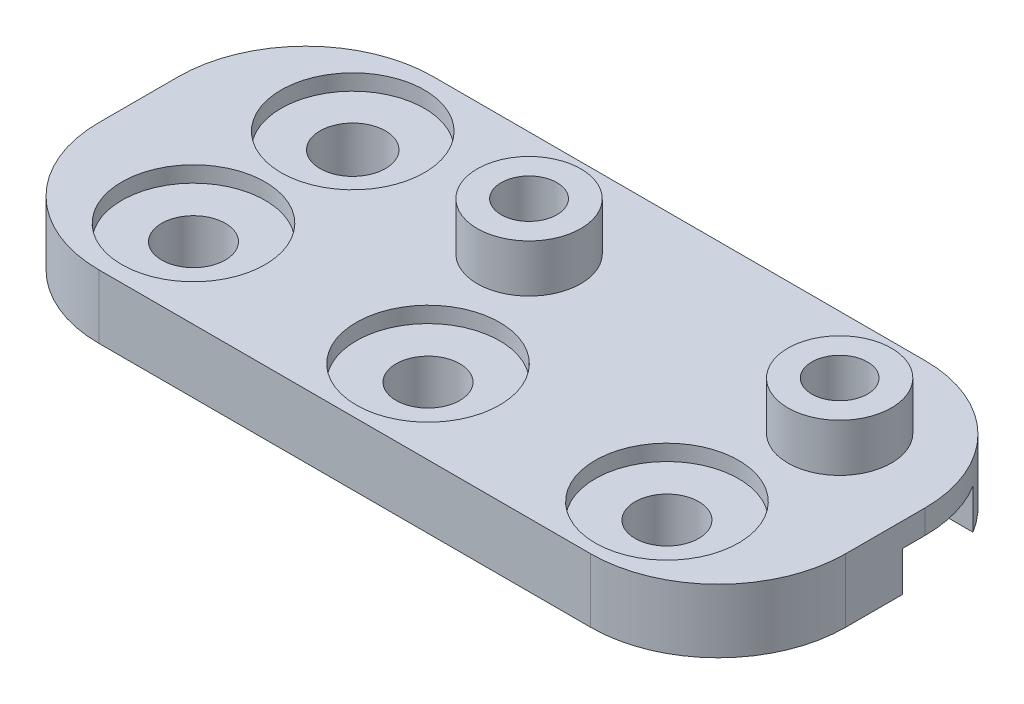
from build123d import *

# Parameters (mm, degrees)
SKETCH2_W           = 46.883828082
SKETCH2_H           = 21
SKETCH2_R           = 2
SKETCH2_R_2         = 2.054050428
SKETCH2_R_3         = 3.25
BOSS_EXTRUDE2_DEPTH = 4
SKETCH2_2_R         = 3.25
BOSS_EXTRUDE3_DEPTH = 7
CUT_EXTRUDE1_REACH  = 9
SKETCH1_R           = 1.75
HOLE1_D             = 4
HOLE1_DEPTH         = 4
HOLE1_CBORE_D       = 9
HOLE1_CBORE_DEPTH   = 1
FILLET1_R           = 8
SKETCH6_R           = 1.75
CUT_EXTRUDE2_DEPTH  = 2.5


with BuildPart() as part:
    # Sketch2 → Boss-Extrude2 (new body)
    with BuildSketch(Plane(origin=(0, 0, 0), x_dir=(1, 0, 0), z_dir=(0, 1, 0))):
        with Locations((0, 1.329477691)):
            Rectangle(SKETCH2_W, SKETCH2_H)
        with Locations((-14.997509842, -3.670522309)):
            Circle(SKETCH2_R, mode=Mode.SUBTRACT)
        with Locations((-14.997509842, 6.329477691)):
            Circle(SKETCH2_R_2, mode=Mode.SUBTRACT)
        with Locations((-2.8, 5.2)):
            Circle(SKETCH2_R_3, mode=Mode.SUBTRACT)
        with Locations((0, -3.943832634)):
            Circle(SKETCH2_R, mode=Mode.SUBTRACT)
        with Locations((16.7, 5.2)):
            Circle(SKETCH2_R_3, mode=Mode.SUBTRACT)
    extrude(amount=BOSS_EXTRUDE2_DEPTH)

    # Sketch2_2 → Boss-Extrude3 (add)
    with BuildSketch(Plane(origin=(0, 0, 0), x_dir=(1, 0, 0), z_dir=(0, 1, 0))):
        with Locations((-2.8, 5.2)):
            Circle(SKETCH2_2_R)
        with Locations((16.7, 5.2)):
            Circle(SKETCH2_2_R)
    extrude(amount=BOSS_EXTRUDE3_DEPTH)

    # Sketch1 → Cut-Extrude1 (cut, up to next)
    with BuildSketch(Plane(origin=(0, 0, 0), x_dir=(1, 0, 0), z_dir=(0, 1, 0)), mode=Mode.PRIVATE) as cut_extrude1_sk1:
        with Locations((-2.8, 5.2)):
            Circle(SKETCH1_R)
    cut_extrude1_tool1 = extrude(cut_extrude1_sk1.sketch, amount=CUT_EXTRUDE1_REACH, mode=Mode.PRIVATE) & part.part
    add(cut_extrude1_tool1.solids().sort_by_distance((-2.8, 0, -5.2))[0], mode=Mode.SUBTRACT)
    # Sketch1 → Cut-Extrude1 (cut, up to next)
    with BuildSketch(Plane(origin=(0, 0, 0), x_dir=(1, 0, 0), z_dir=(0, 1, 0)), mode=Mode.PRIVATE) as cut_extrude1_sk2:
        with Locations((16.7, 5.2)):
            Circle(SKETCH1_R)
    cut_extrude1_tool2 = extrude(cut_extrude1_sk2.sketch, amount=CUT_EXTRUDE1_REACH, mode=Mode.PRIVATE) & part.part
    add(cut_extrude1_tool2.solids().sort_by_distance((16.7, 0, -5.2))[0], mode=Mode.SUBTRACT)

    # Hole1
    with Locations(Plane(origin=(0, 4, 0), x_dir=(1, 0, 0), z_dir=(0, 1, 0))):
        with Locations((0, -3.943832634), (15, -3.943832634), (-14.997509842, -3.670522309), (-14.997509842, 6.329477691)):
            CounterBoreHole(HOLE1_D / 2, HOLE1_CBORE_D / 2, HOLE1_CBORE_DEPTH, depth=HOLE1_DEPTH)

    # Fillet1
    fillet1_edges = [part.edges().sort_by_distance(p)[0] for p in [
        (23.441914041, 2, -11.829477691),
        (23.441914041, 2, 9.170522309),
        (-23.441914041, 2, 9.170522309),
        (-23.441914041, 2, -11.829477691),
    ]]
    fillet(fillet1_edges, radius=FILLET1_R)

    # Sketch6 → Cut-Extrude2 (cut)
    with BuildSketch(Plane.XZ):
        with BuildLine():
            Line((19.933161507, -5.2), (18.316580754, -8))
            Line((18.316580754, -8), (22.268827229, -8))
            ThreePointArc((22.268827229, -8), (23.143060238, -5.995660336), (23.441914041, -3.829477691))
            Line((23.441914041, -3.829477691), (23.441914041, -2.4))
            Line((23.441914041, -2.4), (18.316580754, -2.4))
            Line((18.316580754, -2.4), (19.933161507, -5.2))
        make_face()
        Polygon((13.466838493, -5.2), (15.083419246, -8), (18.316580754, -8), (19.933161507, -5.2), (18.316580754, -2.4), (15.083419246, -2.4), align=None)
        with Locations((16.7, -5.2)):
            Circle(SKETCH6_R, mode=Mode.SUBTRACT)
        Polygon((0.433161507, -5.2), (-1.183419246, -8), (15.083419246, -8), (13.466838493, -5.2), (15.083419246, -2.4), (-1.183419246, -2.4), align=None)
        Polygon((-4.416580754, -2.4), (-6.033161507, -5.2), (-4.416580754, -8), (-1.183419246, -8), (0.433161507, -5.2), (-1.183419246, -2.4), align=None)
        with Locations((-2.8, -5.2)):
            Circle(SKETCH6_R, mode=Mode.SUBTRACT)
        Polygon((-6.033161507, -2.4), (-6.033161507, -5.2), (-4.416580754, -2.4), align=None)
        Polygon((-6.033161507, -5.2), (-6.033161507, -8), (-4.416580754, -8), align=None)
    extrude(amount=-CUT_EXTRUDE2_DEPTH, mode=Mode.SUBTRACT)


solid = part.part
